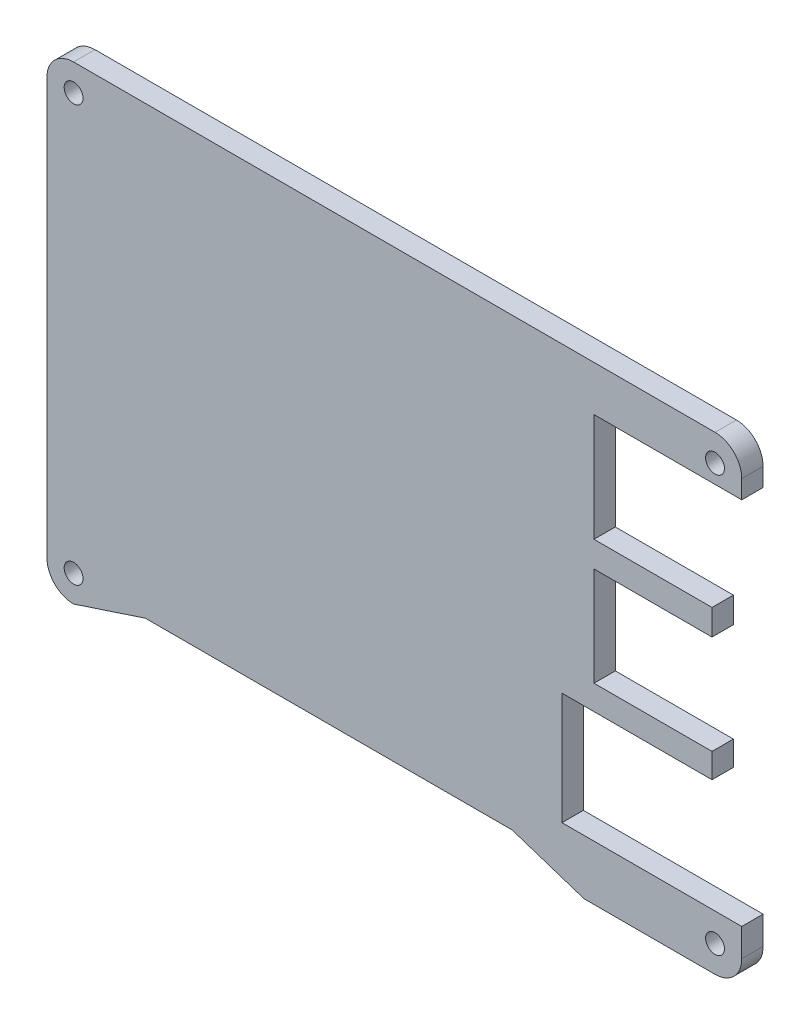
from build123d import *

# Parameters (mm, degrees)
SKETCH1_R           = 1.3462
SKETCH1_W           = 60.6932
SKETCH1_H           = 7.81
SKETCH1_W_2         = 5.588
SKETCH1_H_2         = 23.368
SKETCH1_W_3         = 5.4034
SKETCH1_H_3         = 22.6066
BOSS_EXTRUDE1_DEPTH = 3.048
SKETCH2_R           = 10.922
SKETCH2_R_2         = 1.4986
CUT_EXTRUDE1_DEPTH  = 4.048
SKETCH3_W           = 60.6932
SKETCH3_H           = 56.8638
BOSS_EXTRUDE2_DEPTH = 3.048


with BuildPart() as part:
    # Sketch1 → Boss-Extrude1 (new body)
    with BuildSketch(Plane.XY):
        with BuildLine():
            Line((61.214907375, 24.068294304), (40.134807375, 24.068294304))
            Line((40.134807375, 24.068294304), (40.134807375, 8.658194304))
            Line((40.134807375, 8.658194304), (56.975007375, 8.658194304))
            Line((56.975007375, 8.658194304), (56.975007375, 4.997894304))
            Line((56.975007375, 4.997894304), (40.134807375, 4.997894304))
            Line((40.134807375, 4.997894304), (40.134807375, -9.121805696))
            Line((40.134807375, -9.121805696), (56.975007375, -9.121805696))
            Line((56.975007375, -9.121805696), (56.975007375, -12.628005696))
            Line((56.975007375, -12.628005696), (35.575007375, -12.628005696))
            Line((35.575007375, -12.628005696), (35.575007375, -28.627805696))
            Line((35.575007375, -28.627805696), (61.214907375, -28.627805696))
            Line((61.214907375, -28.627805696), (61.214907375, -32.613401529))
            ThreePointArc((61.214907375, -32.613401529), (60.108826144, -35.325305244), (57.405007375, -36.451005696))
            Line((57.405007375, -36.451005696), (38.714307375, -36.451005696))
            Line((38.714307375, -36.451005696), (28.474307375, -33.084405696))
            Line((28.474307375, -33.084405696), (-23.844892625, -33.084405696))
            Line((-23.844892625, -33.084405696), (-34.084892625, -36.451005696))
            ThreePointArc((-34.084892625, -36.451005696), (-36.778969461, -35.335082532), (-37.894892625, -32.641005696))
            Line((-37.894892625, -32.641005696), (-37.894892625, 26.697694304))
            ThreePointArc((-37.894892625, 26.697694304), (-36.778969461, 29.391771141), (-34.084892625, 30.507694304))
            Line((-34.084892625, 30.507694304), (57.404932375, 30.507694304))
            ThreePointArc((57.404932375, 30.507694304), (60.103884597, 29.386886916), (61.214907375, 26.683892153))
            Line((61.214907375, 26.683892153), (61.214907375, 24.068294304))
        make_face()
        with Locations((57.404932375, 26.697694304)):
            Circle(SKETCH1_R, mode=Mode.SUBTRACT)
        with Locations((-34.084892625, 26.697694304)):
            Circle(SKETCH1_R, mode=Mode.SUBTRACT)
        with Locations((-34.084892625, -32.641005696)):
            Circle(SKETCH1_R, mode=Mode.SUBTRACT)
        with Locations((57.405007375, -32.641005696)):
            Circle(SKETCH1_R, mode=Mode.SUBTRACT)
        with Locations((1.341707375, 21.991994304)):
            Rectangle(SKETCH1_W, SKETCH1_H, mode=Mode.SUBTRACT)
        with Locations((-26.210892625, -1.882805696)):
            Rectangle(SKETCH1_W_2, SKETCH1_H_2, mode=Mode.SUBTRACT)
        with Locations((16.546707375, -19.663505696)):
            Rectangle(SKETCH1_W_3, SKETCH1_H_3, mode=Mode.SUBTRACT)
    extrude(amount=BOSS_EXTRUDE1_DEPTH)

    # Sketch2 → Cut-Extrude1 (cut, through all)
    with BuildSketch(Plane.XY.offset(3.048)):
        with Locations((-0.302892625, -0.480305696)):
            Circle(SKETCH2_R)
        with Locations((-10.285092625, -10.462505696)):
            Circle(SKETCH2_R_2)
        with Locations((-10.285092625, 9.501894304)):
            Circle(SKETCH2_R_2)
        with Locations((9.679307375, -10.462505696)):
            Circle(SKETCH2_R_2)
        with Locations((9.679307375, 9.501894304)):
            Circle(SKETCH2_R_2)
    extrude(amount=-CUT_EXTRUDE1_DEPTH, mode=Mode.SUBTRACT)

    # Sketch3 → Boss-Extrude2 (add)
    with BuildSketch(Plane.XY.offset(3.048)):
        with Locations((1.341707375, -2.534905696)):
            Rectangle(SKETCH3_W, SKETCH3_H)
    extrude(amount=-BOSS_EXTRUDE2_DEPTH)


solid = part.part
